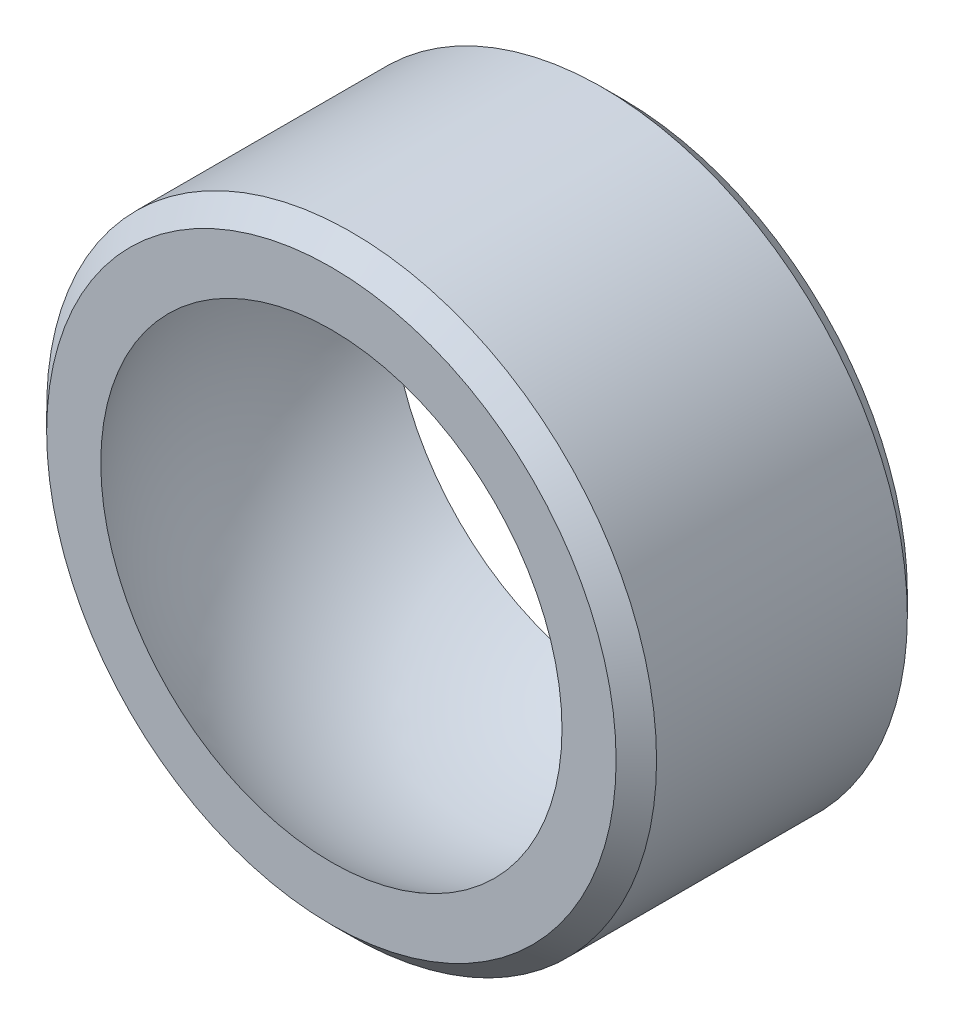
from build123d import *

# Parameters (mm, degrees)
EXTRUDE1_START = -7.2009
SKETCH1_R      = 15.08125
SKETCH1_R_2    = 7.95
EXTRUDE1_DEPTH = 14.4018
CHAMFER1_SIZE  = 1


with BuildPart() as part:
    # Sketch1 → Extrude1 (new body)
    with BuildSketch(Plane.XY.offset(EXTRUDE1_START)):
        Circle(SKETCH1_R)
        Circle(SKETCH1_R_2, mode=Mode.SUBTRACT)
    extrude(amount=EXTRUDE1_DEPTH)

    # Chamfer1
    chamfer1_edges = [part.edges().sort_by_distance(p)[0] for p in [
        (-15.08125, 0, -7.2009),
        (-15.08125, 0, 7.2009),
    ]]
    chamfer(chamfer1_edges, length=CHAMFER1_SIZE)

    # Sketch2 → Revolve1 (revolve)
    with BuildSketch(Plane(origin=(0, 0, 0), x_dir=(0, 0, -1), z_dir=(1, 0, 0))):
        with BuildLine():
            Line((7.95, 7.94), (-7.95, 7.94))
            Line((-7.95, 7.94), (-7.95, 10.895295258))
            ThreePointArc((-7.95, 10.895295258), (0, 13.4874), (7.95, 10.895295258))
            Line((7.95, 10.895295258), (7.95, 7.94))
        make_face()
    revolve(axis=Axis((0, 0, -11.466432169), (0, 0, 1)))

    # Sketch2_2 → Cut-Revolve1 (revolve, cut)
    with BuildSketch(Plane(origin=(0, 0, 0), x_dir=(0, 0, -1), z_dir=(1, 0, 0))):
        with BuildLine():
            Line((7.95, 7.94), (-7.95, 7.94))
            Line((-7.95, 7.94), (-7.95, 10.895295258))
            ThreePointArc((-7.95, 10.895295258), (0, 13.4874), (7.95, 10.895295258))
            Line((7.95, 10.895295258), (7.95, 7.94))
        make_face()
    revolve(axis=Axis((0, 0, -11.466432169), (0, 0, 1)), mode=Mode.SUBTRACT)


solid = part.part
